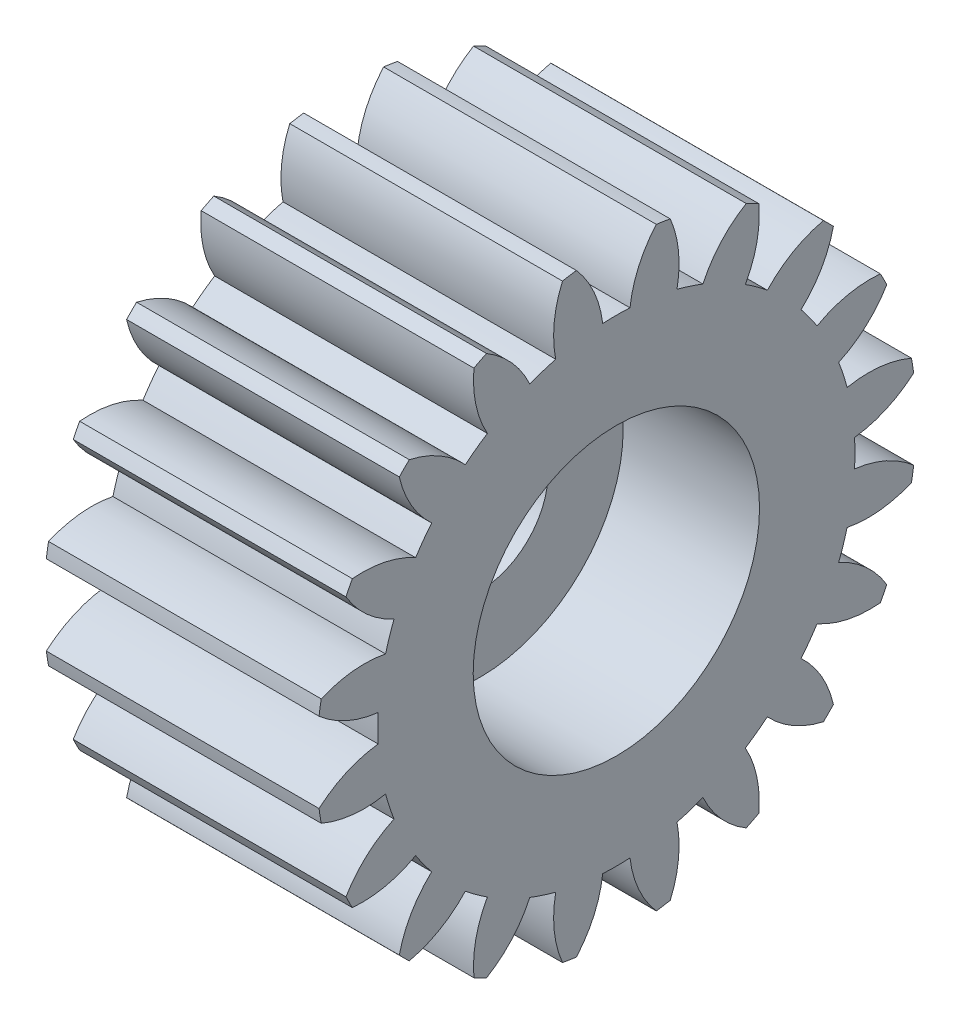
from build123d import *

# Parameters (mm, degrees)
BASPROSKE_W                   = 10
BASPROSKE_H                   = 11
TOOTHCUT_DEPTH                = 19.493242009
TEETHCUTS_COUNT               = 20
TEETHCUTS_ANGLE               = 342
BORSKE_R                      = 0.4
BORE_DEPTH                    = 50.0000508
TALADRO_DE_MARGEN_PARA_M101_D = 10.5
CROQUIS3_R                    = 5.25
CROQUIS3_R_2                  = 2.5
SALIENTE_EXTRUIR1_DEPTH       = 5


with BuildPart() as part:
    # BasProSke → Base-Revolve (revolve)
    with BuildSketch(Plane(origin=(0, 0, 0), x_dir=(1, 0, 0), z_dir=(0, 1, 0)), mode=Mode.PRIVATE) as base_revolve_sk:
        with Locations((5, 5.5)):
            Rectangle(BASPROSKE_W, BASPROSKE_H)
    revolve(base_revolve_sk.sketch.rotate(Axis((-10, 0, 0), (1, 0, 0)), 180), axis=Axis((-10, 0, 0), (1, 0, 0)))

    # TooCutSke → ToothCut (cut, through all)
    with BuildSketch(Plane(origin=(0, 0, 0), x_dir=(0, 0, -1), z_dir=(1, 0, 0))):
        with BuildLine():
            ThreePointArc((0.499924007, 8.734705318), (0, 8.749), (-0.499924007, 8.734705318))
            ThreePointArc((-0.499924007, 8.734705318), (-0.824302243, 9.905497836), (-1.485192705, 10.924909509))
            ThreePointArc((-1.485192705, 10.924909509), (0, 11.0254), (1.485192705, 10.924909509))
            ThreePointArc((1.485192705, 10.924909509), (0.824302243, 9.905497836), (0.499924007, 8.734705318))
        make_face()
    toothcut = extrude(amount=TOOTHCUT_DEPTH, mode=Mode.SUBTRACT)

    # TeethCuts: ToothCut ×20 about axis
    teethcuts_axis = Axis((-10, 0, 0), (1, 0, 0))
    for i in range(1, TEETHCUTS_COUNT):
        add(toothcut.rotate(teethcuts_axis, i * TEETHCUTS_ANGLE / (TEETHCUTS_COUNT - 1)), mode=Mode.SUBTRACT)

    # BorSke → Bore (cut, symmetric)
    with BuildSketch(Plane(origin=(0, 0, 0), x_dir=(0, 0, -1), z_dir=(1, 0, 0))):
        with Locations(Location((0, 0, 0), (0, 0, 180))):
            Circle(BORSKE_R)
    extrude(amount=BORE_DEPTH, both=True, mode=Mode.SUBTRACT)

    # Taladro de margen para M101 (through all)
    with Locations(Plane(origin=(10, 0, 0), x_dir=(0, 0, -1), z_dir=(1, 0, 0))):
        with Locations((0, 0)):
            Hole(TALADRO_DE_MARGEN_PARA_M101_D / 2)

    # Croquis3 → Saliente-Extruir1 (add)
    with BuildSketch(Plane.ZY):
        with Locations(Location((0, 0, 0), (0, 0, 180))):
            Circle(CROQUIS3_R)
        Circle(CROQUIS3_R_2, mode=Mode.SUBTRACT)
    extrude(amount=-SALIENTE_EXTRUIR1_DEPTH)


solid = part.part
